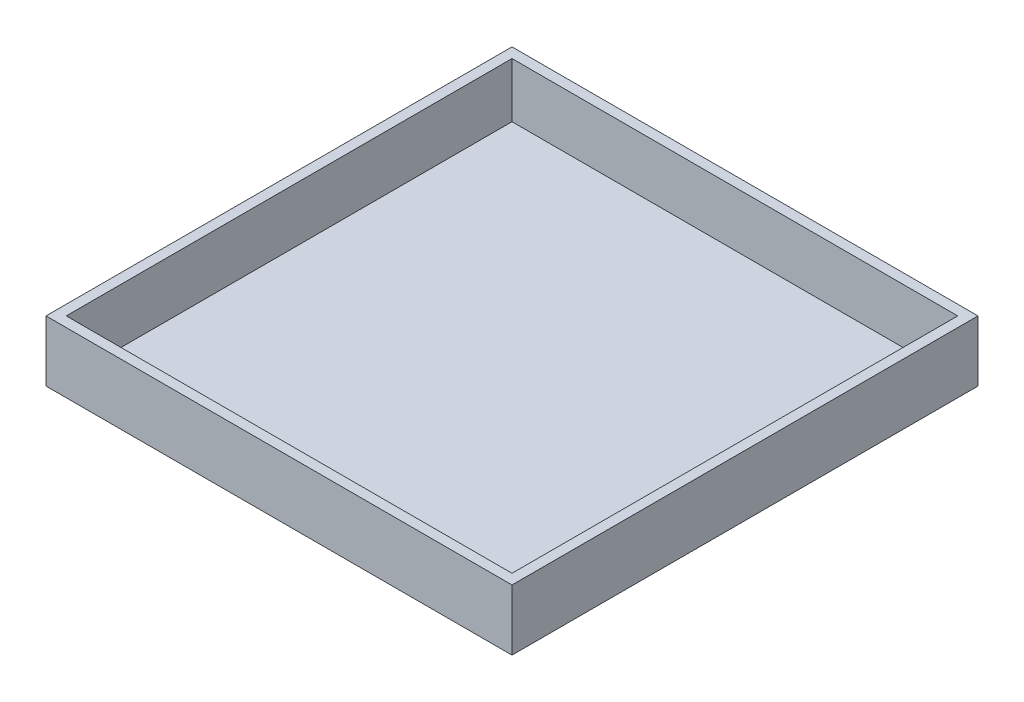
from build123d import *

# Parameters (mm, degrees)
SKETCH_1_W      = 220
SKETCH_1_H      = 220
EXTRUDE_1_DEPTH = 3
SKETCH_2_W      = 230
SKETCH_2_H      = 230
SKETCH_2_W_2    = 220
SKETCH_2_H_2    = 220
EXTRUDE_2_DEPTH = 30


with BuildPart() as part:
    # Эскиз1 → Бобышка-Вытянуть1 (new body)
    with BuildSketch(Plane(origin=(0, 0, 0), x_dir=(1, 0, 0), z_dir=(0, 1, 0))):
        Rectangle(SKETCH_1_W, SKETCH_1_H)
    extrude(amount=EXTRUDE_1_DEPTH)

    # Эскиз2 → Бобышка-Вытянуть2 (add)
    with BuildSketch(Plane(origin=(0, 0, 0), x_dir=(1, 0, 0), z_dir=(0, 1, 0))):
        Rectangle(SKETCH_2_W, SKETCH_2_H)
        Rectangle(SKETCH_2_W_2, SKETCH_2_H_2, mode=Mode.SUBTRACT)
    extrude(amount=EXTRUDE_2_DEPTH)


solid = part.part
